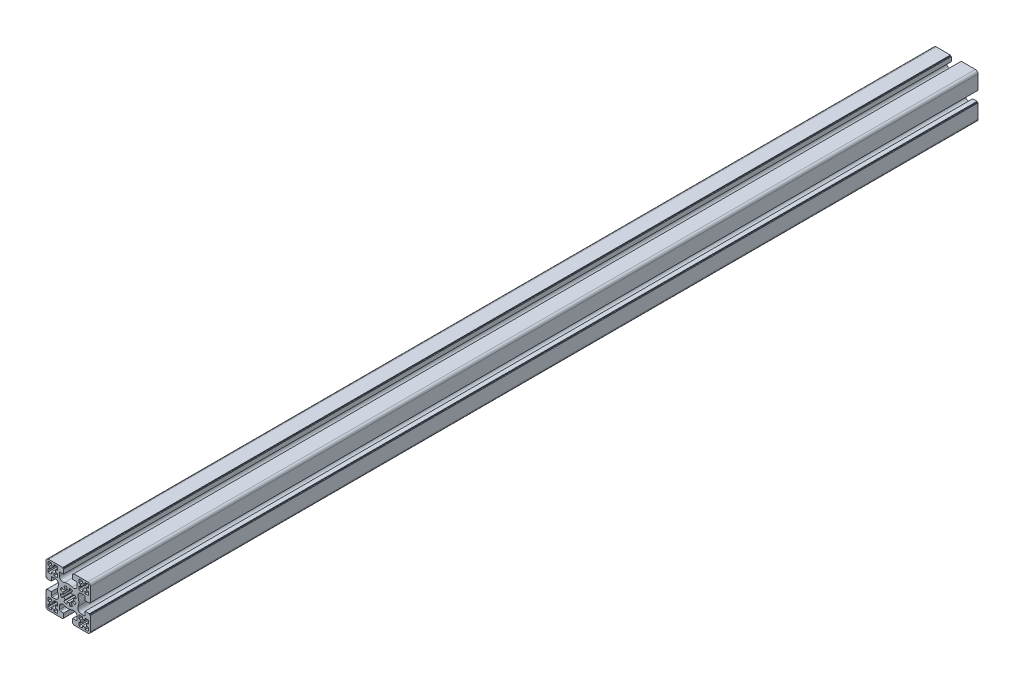
from build123d import *

# Parameters (mm, degrees)
EXTRUDE_1_DEPTH = 1000


with BuildPart() as part:
    # 草图1 → 拉伸1 (new body)
    with BuildSketch(Plane.XY):
        with BuildLine():
            Line((16.49685499, 66.688953887), (16.49685499, 63.521350861))
            ThreePointArc((16.49685499, 63.521350861), (18.260787013, 60.204726071), (21.99685499, 59.813251618))
            ThreePointArc((21.99685499, 59.813251618), (26.49685499, 60.688953887), (30.99685499, 59.813251618))
            ThreePointArc((30.99685499, 59.813251618), (34.732922968, 60.204726071), (36.49685499, 63.521350861))
            Line((36.49685499, 63.521350861), (36.49685499, 66.688953887))
            ThreePointArc((36.49685499, 66.688953887), (36.203961772, 67.396060668), (35.49685499, 67.688953887))
            Line((35.49685499, 67.688953887), (31.59685499, 67.688953887))
            Line((31.59685499, 67.688953887), (31.59685499, 72.688953887))
            Line((31.59685499, 72.688953887), (32.59685499, 72.688953887))
            Line((32.59685499, 72.688953887), (32.59685499, 73.688953887))
            Line((32.59685499, 73.688953887), (48.496854991, 73.688953887))
            ThreePointArc((48.496854991, 73.688953887), (50.618175334, 72.810274231), (51.496854991, 70.688953887))
            Line((51.496854991, 70.688953887), (51.496854991, 54.788953887))
            Line((51.496854991, 54.788953887), (50.496854991, 54.788953887))
            Line((50.496854991, 54.788953887), (50.496854991, 53.788953887))
            Line((50.496854991, 53.788953887), (45.496854991, 53.788953887))
            Line((45.496854991, 53.788953887), (45.496854991, 57.688953887))
            ThreePointArc((45.496854991, 57.688953887), (45.203961772, 58.396060668), (44.496854991, 58.688953887))
            Line((44.496854991, 58.688953887), (41.329251965, 58.688953887))
            ThreePointArc((41.329251965, 58.688953887), (38.012627174, 56.925021864), (37.621152721, 53.188953887))
            ThreePointArc((37.621152721, 53.188953887), (38.49685499, 48.688953887), (37.621152721, 44.188953887))
            ThreePointArc((37.621152721, 44.188953887), (38.012627174, 40.452885909), (41.329251965, 38.688953887))
            Line((41.329251965, 38.688953887), (44.496854991, 38.688953887))
            ThreePointArc((44.496854991, 38.688953887), (45.203961772, 38.981847106), (45.496854991, 39.688953887))
            Line((45.496854991, 39.688953887), (45.496854991, 43.588953887))
            Line((45.496854991, 43.588953887), (50.496854991, 43.588953887))
            Line((50.496854991, 43.588953887), (50.496854991, 42.588953887))
            Line((50.496854991, 42.588953887), (51.496854991, 42.588953887))
            Line((51.496854991, 42.588953887), (51.496854991, 26.688953887))
            ThreePointArc((51.496854991, 26.688953887), (50.618175334, 24.567633543), (48.496854991, 23.688953887))
            Line((48.496854991, 23.688953887), (32.59685499, 23.688953887))
            Line((32.59685499, 23.688953887), (32.59685499, 24.688953887))
            Line((32.59685499, 24.688953887), (31.59685499, 24.688953887))
            Line((31.59685499, 24.688953887), (31.59685499, 29.688953887))
            Line((31.59685499, 29.688953887), (35.49685499, 29.688953887))
            ThreePointArc((35.49685499, 29.688953887), (36.203961772, 29.981847106), (36.49685499, 30.688953887))
            Line((36.49685499, 30.688953887), (36.49685499, 33.856556913))
            ThreePointArc((36.49685499, 33.856556913), (34.732922968, 37.173181703), (30.99685499, 37.564656156))
            ThreePointArc((30.99685499, 37.564656156), (26.49685499, 36.688953887), (21.99685499, 37.564656156))
            ThreePointArc((21.99685499, 37.564656156), (18.260787013, 37.173181703), (16.49685499, 33.856556913))
            Line((16.49685499, 33.856556913), (16.49685499, 30.688953887))
            ThreePointArc((16.49685499, 30.688953887), (16.789748209, 29.981847106), (17.49685499, 29.688953887))
            Line((17.49685499, 29.688953887), (21.396854991, 29.688953887))
            Line((21.396854991, 29.688953887), (21.396854991, 24.688953887))
            Line((21.396854991, 24.688953887), (20.396854991, 24.688953887))
            Line((20.396854991, 24.688953887), (20.396854991, 23.688953887))
            Line((20.396854991, 23.688953887), (4.49685499, 23.688953887))
            ThreePointArc((4.49685499, 23.688953887), (2.375534647, 24.567633543), (1.49685499, 26.688953887))
            Line((1.49685499, 26.688953887), (1.49685499, 42.588953887))
            Line((1.49685499, 42.588953887), (2.49685499, 42.588953887))
            Line((2.49685499, 42.588953887), (2.49685499, 43.588953887))
            Line((2.49685499, 43.588953887), (7.49685499, 43.588953887))
            Line((7.49685499, 43.588953887), (7.49685499, 39.688953887))
            ThreePointArc((7.49685499, 39.688953887), (7.789748209, 38.981847106), (8.49685499, 38.688953887))
            Line((8.49685499, 38.688953887), (11.664458016, 38.688953887))
            ThreePointArc((11.664458016, 38.688953887), (14.981082806, 40.452885909), (15.37255726, 44.188953887))
            ThreePointArc((15.37255726, 44.188953887), (14.49685499, 48.688953887), (15.37255726, 53.188953887))
            ThreePointArc((15.37255726, 53.188953887), (14.981082806, 56.925021864), (11.664458016, 58.688953887))
            Line((11.664458016, 58.688953887), (8.49685499, 58.688953887))
            ThreePointArc((8.49685499, 58.688953887), (7.789748209, 58.396060668), (7.49685499, 57.688953887))
            Line((7.49685499, 57.688953887), (7.49685499, 53.788953887))
            Line((7.49685499, 53.788953887), (2.49685499, 53.788953887))
            Line((2.49685499, 53.788953887), (2.49685499, 54.788953887))
            Line((2.49685499, 54.788953887), (1.49685499, 54.788953887))
            Line((1.49685499, 54.788953887), (1.49685499, 70.688953887))
            ThreePointArc((1.49685499, 70.688953887), (2.375534647, 72.810274231), (4.49685499, 73.688953887))
            Line((4.49685499, 73.688953887), (20.396854991, 73.688953887))
            Line((20.396854991, 73.688953887), (20.396854991, 72.688953887))
            Line((20.396854991, 72.688953887), (21.396854991, 72.688953887))
            Line((21.396854991, 72.688953887), (21.396854991, 67.688953887))
            Line((21.396854991, 67.688953887), (17.49685499, 67.688953887))
            ThreePointArc((17.49685499, 67.688953887), (16.789748209, 67.396060668), (16.49685499, 66.688953887))
        make_face()
        with BuildLine():
            Line((20.612143308, 47.518411955), (17.669787467, 46.933140989))
            ThreePointArc((17.669787467, 46.933140989), (18.181939198, 45.244802996), (19.01362848, 43.68882179))
            Line((19.01362848, 43.68882179), (21.508037317, 45.355532489))
            ThreePointArc((21.508037317, 45.355532489), (22.254214303, 44.4463132), (23.163433592, 43.700136213))
            Line((23.163433592, 43.700136213), (21.496722893, 41.205727376))
            ThreePointArc((21.496722893, 41.205727376), (23.052704099, 40.374038094), (24.741042092, 39.861886363))
            Line((24.741042092, 39.861886363), (25.326313058, 42.804242205))
            ThreePointArc((25.326313058, 42.804242205), (26.49685499, 42.688953887), (27.667396922, 42.804242205))
            Line((27.667396922, 42.804242205), (28.252667889, 39.861886363))
            ThreePointArc((28.252667889, 39.861886363), (29.941005882, 40.374038094), (31.496987087, 41.205727376))
            Line((31.496987087, 41.205727376), (29.830276388, 43.700136213))
            ThreePointArc((29.830276388, 43.700136213), (30.739495677, 44.4463132), (31.485672664, 45.355532489))
            Line((31.485672664, 45.355532489), (33.980081501, 43.68882179))
            ThreePointArc((33.980081501, 43.68882179), (34.811770783, 45.244802996), (35.323922514, 46.933140989))
            Line((35.323922514, 46.933140989), (32.381566673, 47.518411955))
            ThreePointArc((32.381566673, 47.518411955), (32.49685499, 48.688953887), (32.381566673, 49.859495819))
            Line((32.381566673, 49.859495819), (35.323922514, 50.444766785))
            ThreePointArc((35.323922514, 50.444766785), (34.811770783, 52.133104778), (33.980081501, 53.689085984))
            Line((33.980081501, 53.689085984), (31.485672664, 52.022375285))
            ThreePointArc((31.485672664, 52.022375285), (30.739495677, 52.931594574), (29.830276388, 53.677771561))
            Line((29.830276388, 53.677771561), (31.496987088, 56.172180398))
            ThreePointArc((31.496987088, 56.172180398), (29.941005882, 57.00386968), (28.252667889, 57.516021411))
            Line((28.252667889, 57.516021411), (27.667396922, 54.573665569))
            ThreePointArc((27.667396922, 54.573665569), (26.49685499, 54.688953887), (25.326313058, 54.573665569))
            Line((25.326313058, 54.573665569), (24.741042092, 57.516021411))
            ThreePointArc((24.741042092, 57.516021411), (23.052704099, 57.00386968), (21.496722893, 56.172180398))
            Line((21.496722893, 56.172180398), (23.163433592, 53.677771561))
            ThreePointArc((23.163433592, 53.677771561), (22.254214303, 52.931594574), (21.508037317, 52.022375285))
            Line((21.508037317, 52.022375285), (19.01362848, 53.689085984))
            ThreePointArc((19.01362848, 53.689085984), (18.181939198, 52.133104778), (17.669787467, 50.444766785))
            Line((17.669787467, 50.444766785), (20.612143308, 49.859495819))
            ThreePointArc((20.612143308, 49.859495819), (20.49685499, 48.688953887), (20.612143308, 47.518411955))
        make_face(mode=Mode.SUBTRACT)
        with BuildLine():
            Line((3.49685499, 29.688953887), (3.49685499, 26.688953887))
            ThreePointArc((3.49685499, 26.688953887), (3.789748209, 25.981847106), (4.49685499, 25.688953887))
            Line((4.49685499, 25.688953887), (7.49685499, 25.688953887))
            Line((7.49685499, 25.688953887), (7.49685499, 27.788953887))
            Line((7.49685499, 27.788953887), (10.49685499, 27.788953887))
            Line((10.49685499, 27.788953887), (10.49685499, 25.688953887))
            Line((10.49685499, 25.688953887), (14.496854991, 25.688953887))
            Line((14.496854991, 25.688953887), (14.496854991, 29.688953887))
            Line((14.496854991, 29.688953887), (12.396854991, 29.688953887))
            Line((12.396854991, 29.688953887), (12.396854991, 32.688953887))
            Line((12.396854991, 32.688953887), (14.49685499, 32.688953887))
            Line((14.49685499, 32.688953887), (14.49685499, 35.688953887))
            ThreePointArc((14.49685499, 35.688953887), (14.203961772, 36.396060669), (13.49685499, 36.688953887))
            Line((13.49685499, 36.688953887), (10.49685499, 36.688953887))
            Line((10.49685499, 36.688953887), (10.49685499, 34.588953887))
            Line((10.49685499, 34.588953887), (7.49685499, 34.588953887))
            Line((7.49685499, 34.588953887), (7.49685499, 36.688953887))
            Line((7.49685499, 36.688953887), (3.49685499, 36.688953887))
            Line((3.49685499, 36.688953887), (3.49685499, 32.688953887))
            Line((3.49685499, 32.688953887), (5.59685499, 32.688953887))
            Line((5.59685499, 32.688953887), (5.59685499, 29.688953887))
            Line((5.59685499, 29.688953887), (3.49685499, 29.688953887))
        make_face(mode=Mode.SUBTRACT)
        with BuildLine():
            Line((45.49685499, 25.688953887), (48.496854991, 25.688953887))
            ThreePointArc((48.496854991, 25.688953887), (49.203961772, 25.981847106), (49.496854991, 26.688953887))
            Line((49.496854991, 26.688953887), (49.496854991, 29.688953887))
            Line((49.496854991, 29.688953887), (47.396854991, 29.688953887))
            Line((47.396854991, 29.688953887), (47.396854991, 32.688953887))
            Line((47.396854991, 32.688953887), (49.496854991, 32.688953887))
            Line((49.496854991, 32.688953887), (49.496854991, 36.688953887))
            Line((49.496854991, 36.688953887), (45.49685499, 36.688953887))
            Line((45.49685499, 36.688953887), (45.49685499, 34.588953887))
            Line((45.49685499, 34.588953887), (42.49685499, 34.588953887))
            Line((42.49685499, 34.588953887), (42.49685499, 36.688953887))
            Line((42.49685499, 36.688953887), (39.49685499, 36.688953887))
            ThreePointArc((39.49685499, 36.688953887), (38.789748209, 36.396060668), (38.49685499, 35.688953887))
            Line((38.49685499, 35.688953887), (38.49685499, 32.688953887))
            Line((38.49685499, 32.688953887), (40.59685499, 32.688953887))
            Line((40.59685499, 32.688953887), (40.59685499, 29.688953887))
            Line((40.59685499, 29.688953887), (38.49685499, 29.688953887))
            Line((38.49685499, 29.688953887), (38.49685499, 25.688953887))
            Line((38.49685499, 25.688953887), (42.49685499, 25.688953887))
            Line((42.49685499, 25.688953887), (42.49685499, 27.788953887))
            Line((42.49685499, 27.788953887), (45.49685499, 27.788953887))
            Line((45.49685499, 27.788953887), (45.49685499, 25.688953887))
        make_face(mode=Mode.SUBTRACT)
        with BuildLine():
            Line((7.49685499, 71.688953887), (4.49685499, 71.688953887))
            ThreePointArc((4.49685499, 71.688953887), (3.789748209, 71.396060668), (3.49685499, 70.688953887))
            Line((3.49685499, 70.688953887), (3.49685499, 67.688953887))
            Line((3.49685499, 67.688953887), (5.59685499, 67.688953887))
            Line((5.59685499, 67.688953887), (5.59685499, 64.688953887))
            Line((5.59685499, 64.688953887), (3.49685499, 64.688953887))
            Line((3.49685499, 64.688953887), (3.49685499, 60.688953887))
            Line((3.49685499, 60.688953887), (7.49685499, 60.688953887))
            Line((7.49685499, 60.688953887), (7.49685499, 62.788953887))
            Line((7.49685499, 62.788953887), (10.49685499, 62.788953887))
            Line((10.49685499, 62.788953887), (10.49685499, 60.688953887))
            Line((10.49685499, 60.688953887), (13.49685499, 60.688953887))
            ThreePointArc((13.49685499, 60.688953887), (14.203961771, 60.981847105), (14.49685499, 61.688953887))
            Line((14.49685499, 61.688953887), (14.49685499, 64.688953886))
            Line((14.49685499, 64.688953886), (12.39685499, 64.688953886))
            Line((12.39685499, 64.688953886), (12.39685499, 67.688953886))
            Line((12.39685499, 67.688953886), (14.49685499, 67.688953886))
            Line((14.49685499, 67.688953886), (14.49685499, 71.688953887))
            Line((14.49685499, 71.688953887), (10.49685499, 71.688953887))
            Line((10.49685499, 71.688953887), (10.49685499, 69.588953887))
            Line((10.49685499, 69.588953887), (7.49685499, 69.588953887))
            Line((7.49685499, 69.588953887), (7.49685499, 71.688953887))
        make_face(mode=Mode.SUBTRACT)
        with BuildLine():
            Line((38.49685499, 64.688953887), (38.49685499, 61.688953887))
            ThreePointArc((38.49685499, 61.688953887), (38.789748209, 60.981847106), (39.49685499, 60.688953887))
            Line((39.49685499, 60.688953887), (42.49685499, 60.688953887))
            Line((42.49685499, 60.688953887), (42.49685499, 62.788953887))
            Line((42.49685499, 62.788953887), (45.49685499, 62.788953887))
            Line((45.49685499, 62.788953887), (45.49685499, 60.688953887))
            Line((45.49685499, 60.688953887), (49.496854991, 60.688953887))
            Line((49.496854991, 60.688953887), (49.496854991, 64.688953887))
            Line((49.496854991, 64.688953887), (47.396854991, 64.688953887))
            Line((47.396854991, 64.688953887), (47.396854991, 67.688953887))
            Line((47.396854991, 67.688953887), (49.496854991, 67.688953887))
            Line((49.496854991, 67.688953887), (49.496854991, 70.688953887))
            ThreePointArc((49.496854991, 70.688953887), (49.203961772, 71.396060668), (48.496854991, 71.688953887))
            Line((48.496854991, 71.688953887), (45.496854991, 71.688953887))
            Line((45.496854991, 71.688953887), (45.496854991, 69.588953887))
            Line((45.496854991, 69.588953887), (42.496854991, 69.588953887))
            Line((42.496854991, 69.588953887), (42.496854991, 71.688953887))
            Line((42.496854991, 71.688953887), (38.49685499, 71.688953887))
            Line((38.49685499, 71.688953887), (38.49685499, 67.688953887))
            Line((38.49685499, 67.688953887), (40.59685499, 67.688953887))
            Line((40.59685499, 67.688953887), (40.59685499, 64.688953887))
            Line((40.59685499, 64.688953887), (38.49685499, 64.688953887))
        make_face(mode=Mode.SUBTRACT)
    extrude(amount=EXTRUDE_1_DEPTH)


solid = part.part
